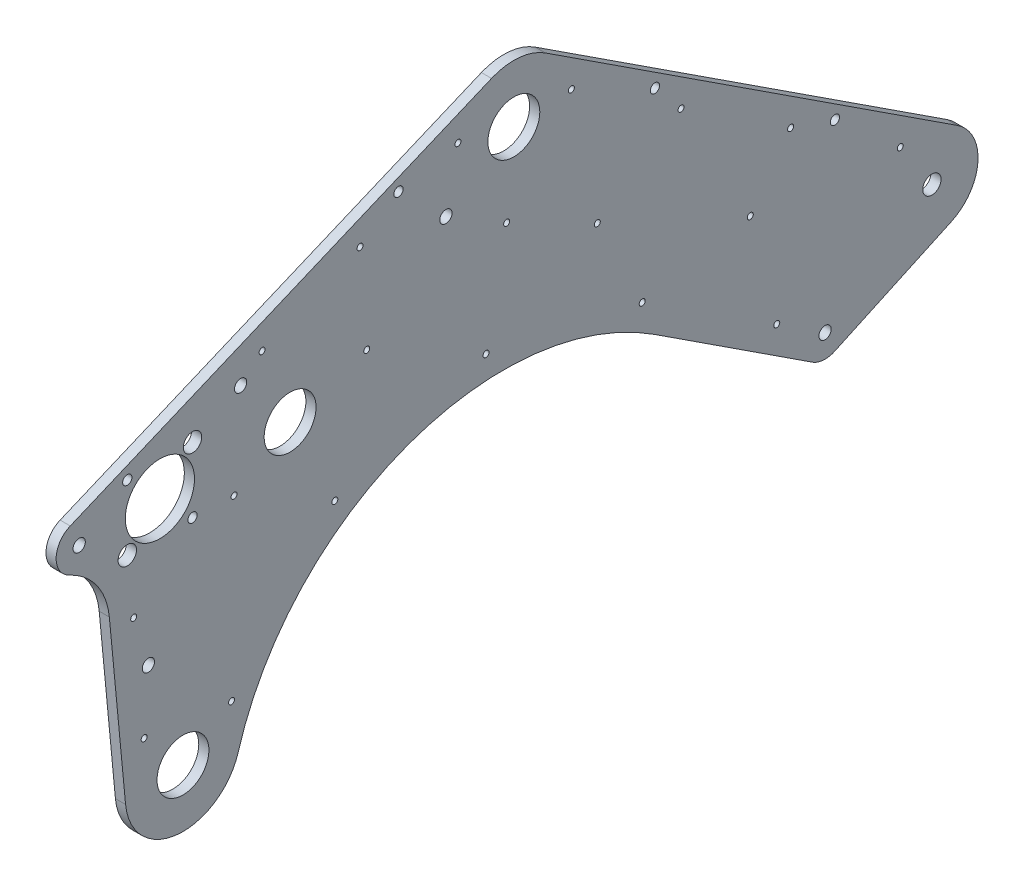
from build123d import *

# Parameters (mm, degrees)
SKETCH2_R           = 14.2875
SKETCH2_R_2         = 19.05
SKETCH2_R_3         = 5.0419
SKETCH2_R_4         = 3.3782
SKETCH2_R_5         = 5.08
SKETCH2_R_6         = 2.5527
BOSS_EXTRUDE1_DEPTH = 5.588
SKETCH4_R           = 2.5527
CUT_EXTRUDE1_DEPTH  = 6.588
SKETCH6_R           = 1.651
CUT_EXTRUDE2_DEPTH  = 6.588


with BuildPart() as part:
    # Sketch2 → Boss-Extrude1 (new body)
    with BuildSketch(Plane(origin=(0, 0, 0), x_dir=(0, 0, -1), z_dir=(1, 0, 0))):
        with BuildLine():
            Line((-444.051224287, -73.655160045), (-452.990991726, 20.219177))
            ThreePointArc((-452.990991726, 20.219177), (-459.828166258, 38.628688745), (-474.92551535, 51.187634905))
            ThreePointArc((-474.92551535, 51.187634905), (-482.292216482, 62.940162968), (-474.512475698, 74.423447984))
            Line((-474.512475698, 74.423447984), (-242.526195837, 171.867023314))
            ThreePointArc((-242.526195837, 171.867023314), (-227.371894365, 174.215557577), (-212.884484768, 169.18729451))
            Line((-212.884484768, 169.18729451), (13.876862492, 21.274225894))
            ThreePointArc((13.876862492, 21.274225894), (25.333435416, -1.837675174), (10.661298989, -23.05421228))
            Line((10.661298989, -23.05421228), (-53.518911784, -52.734012568))
            ThreePointArc((-53.518911784, -52.734012568), (-59.768398865, -53.873624135), (-65.787992524, -51.844019374))
            Line((-65.787992524, -51.844019374), (-152.593044897, 4.777630757))
            ThreePointArc((-152.593044897, 4.777630757), (-288.489875105, 20.154119165), (-381.997670333, -79.649072608))
            ThreePointArc((-381.997670333, -79.649072608), (-415.496829233, -102.248099493), (-444.051224287, -73.655160045))
        make_face()
        with Locations((-230.230562883, 142.594512143)):
            Circle(SKETCH2_R, mode=Mode.SUBTRACT)
        with Locations((-353.440471878, 63.406794563)):
            Circle(SKETCH2_R, mode=Mode.SUBTRACT)
        with Locations((-412.444222517, -70.645186775)):
            Circle(SKETCH2_R, mode=Mode.SUBTRACT)
        with Locations((-425.144222517, 62.714443515)):
            Circle(SKETCH2_R_2, mode=Mode.SUBTRACT)
        Circle(SKETCH2_R_3, mode=Mode.SUBTRACT)
        with Locations((-58.849561279, -41.206906428)):
            Circle(SKETCH2_R_4, mode=Mode.SUBTRACT)
        with Locations((-267.623520866, 118.561842852)):
            Circle(SKETCH2_R_4, mode=Mode.SUBTRACT)
        with Locations((-407.183710275, 80.674955757)):
            Circle(SKETCH2_R_5, mode=Mode.SUBTRACT)
        with Locations((-443.104734759, 80.674955757)):
            Circle(SKETCH2_R_6, mode=Mode.SUBTRACT)
        with Locations((-443.104734759, 44.753931273)):
            Circle(SKETCH2_R_5, mode=Mode.SUBTRACT)
        with Locations((-407.183710275, 44.753931273)):
            Circle(SKETCH2_R_6, mode=Mode.SUBTRACT)
        with Locations((-469.594222517, 62.714443515)):
            Circle(SKETCH2_R_4, mode=Mode.SUBTRACT)
        with Locations((-431.494222517, -13.485556485)):
            Circle(SKETCH2_R_4, mode=Mode.SUBTRACT)
        with Locations((-380.694222517, 94.464443515)):
            Circle(SKETCH2_R_4, mode=Mode.SUBTRACT)
    extrude(amount=BOSS_EXTRUDE1_DEPTH)

    # Sketch4 → Cut-Extrude1 (cut, through all)
    with BuildSketch(Plane(origin=(5.588, 0, 0), x_dir=(0, 0, -1), z_dir=(1, 0, 0))):
        with Locations((-293.761614403, 143.45865083)):
            Circle(SKETCH4_R)
        with Locations((-152.53102271, 122.238150561)):
            Circle(SKETCH4_R)
        with Locations((-53.415030813, 57.586256896)):
            Circle(SKETCH4_R)
    extrude(amount=-CUT_EXTRUDE1_DEPTH, mode=Mode.SUBTRACT)

    # Sketch6 → Cut-Extrude2 (cut, through all)
    with BuildSketch(Plane(origin=(5.588, 0, 0), x_dir=(0, 0, -1), z_dir=(1, 0, 0))):
        with Locations((-17.434256382, 26.535056141)):
            Circle(SKETCH6_R)
        with Locations((-159.544838365, 23.538860962)):
            Circle(SKETCH6_R)
        with Locations((-77.805734295, 65.914477118)):
            Circle(SKETCH6_R)
        with Locations((-245.562662209, 41.946583471)):
            Circle(SKETCH6_R)
        with Locations((-261.025951592, 150.321512483)):
            Circle(SKETCH6_R)
        with Locations((-328.824486777, 13.567386224)):
            Circle(SKETCH6_R)
        with Locations((-385.694231257, -53.542541728)):
            Circle(SKETCH6_R)
        with Locations((-439.565263827, 13.201837119)):
            Circle(SKETCH6_R)
        with Locations((-314.936803191, 127.67678482)):
            Circle(SKETCH6_R)
        with Locations((-368.84765479, 105.032057158)):
            Circle(SKETCH6_R)
        with Locations((-138.177212208, 105.293898095)):
            Circle(SKETCH6_R)
        with Locations((-85.442343646, -23.860828313)):
            Circle(SKETCH6_R)
        with Locations((-433.816402195, -47.165569321)):
            Circle(SKETCH6_R)
        with Locations((-198.54869012, 144.673319072)):
            Circle(SKETCH6_R)
        with Locations((-234.184271033, 98.860730407)):
            Circle(SKETCH6_R)
        with Locations((-384.29522028, 43.783484838)):
            Circle(SKETCH6_R)
        with Locations((-311.243516345, 76.78330883)):
            Circle(SKETCH6_R)
        with Locations((-184.277438268, 73.672869391)):
            Circle(SKETCH6_R)
        with Locations((-100.025478144, 34.964630862)):
            Circle(SKETCH6_R)
    extrude(amount=-CUT_EXTRUDE2_DEPTH, mode=Mode.SUBTRACT)


solid = part.part
